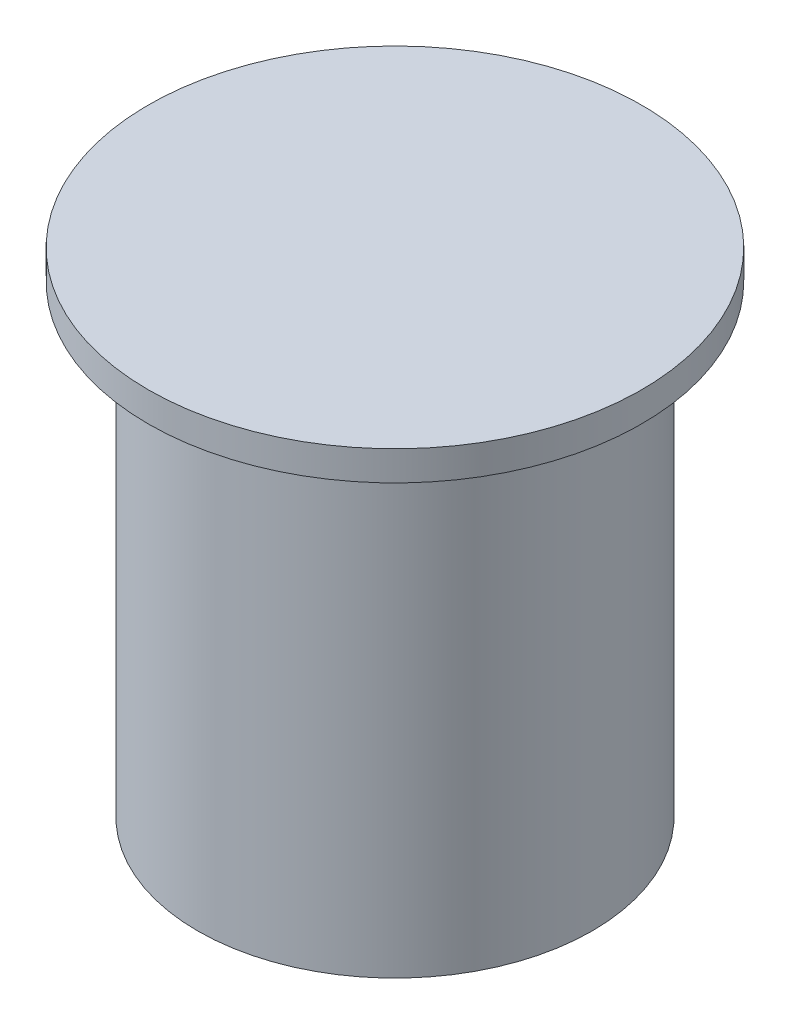
from build123d import *

# Parameters (mm, degrees)
SKETCH_1_R      = 80
EXTRUDE_1_DEPTH = 188
SKETCH_2_R      = 100
EXTRUDE_2_DEPTH = 12


with BuildPart() as part:
    # Эскиз1 → Бобышка-Вытянуть1 (new body)
    with BuildSketch(Plane(origin=(0, 0, 0), x_dir=(1, 0, 0), z_dir=(0, 1, 0))):
        Circle(SKETCH_1_R)
    extrude(amount=EXTRUDE_1_DEPTH)

    # Эскиз2 → Бобышка-Вытянуть2 (add)
    with BuildSketch(Plane(origin=(0, 188, 0), x_dir=(1, 0, 0), z_dir=(0, 1, 0))):
        Circle(SKETCH_2_R)
    extrude(amount=EXTRUDE_2_DEPTH)


solid = part.part
